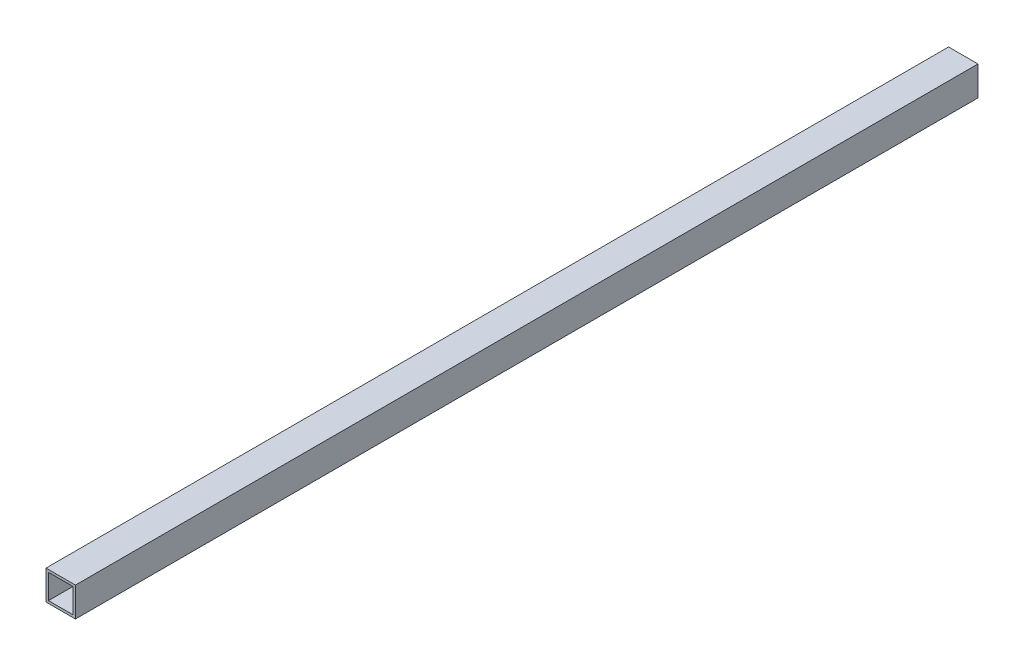
from build123d import *

# Parameters (mm, degrees)
SKETCH2_W           = 19.05
SKETCH2_H           = 19.05
BOSS_EXTRUDE1_DEPTH = 584.2
SKETCH4_W           = 15.875
SKETCH4_H           = 15.875
CUT_EXTRUDE1_DEPTH  = 585.2


with BuildPart() as part:
    # Sketch2 → Boss-Extrude1 (new body)
    with BuildSketch(Plane.XY):
        with Locations((-0.734093805, 5.388919414)):
            Rectangle(SKETCH2_W, SKETCH2_H)
    extrude(amount=BOSS_EXTRUDE1_DEPTH)

    # Sketch4 → Cut-Extrude1 (cut, through all)
    with BuildSketch(Plane(origin=(0, 0, 0), x_dir=(-1, 0, 0), z_dir=(0, 0, -1))):
        with Locations((0.734093805, 5.388919414)):
            Rectangle(SKETCH4_W, SKETCH4_H)
    extrude(amount=-CUT_EXTRUDE1_DEPTH, mode=Mode.SUBTRACT)


solid = part.part
